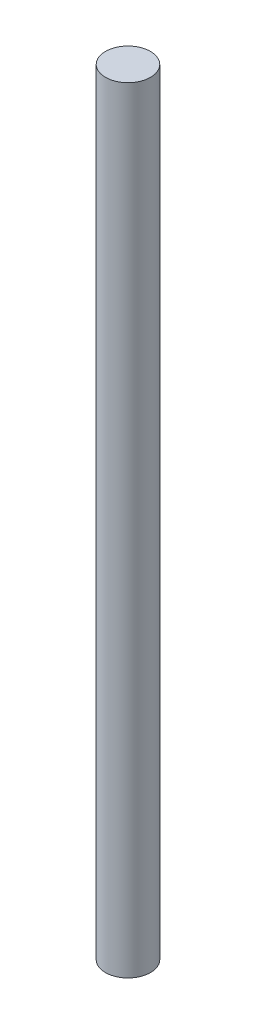
from build123d import *

# Parameters (mm, degrees)
CROQUIS1_R              = 1.45
SALIENTE_EXTRUIR1_DEPTH = 50


with BuildPart() as part:
    # Croquis1 → Saliente-Extruir1 (new body)
    with BuildSketch(Plane(origin=(0, 0, 0), x_dir=(1, 0, 0), z_dir=(0, 1, 0))):
        Circle(CROQUIS1_R)
    extrude(amount=SALIENTE_EXTRUIR1_DEPTH)


solid = part.part
